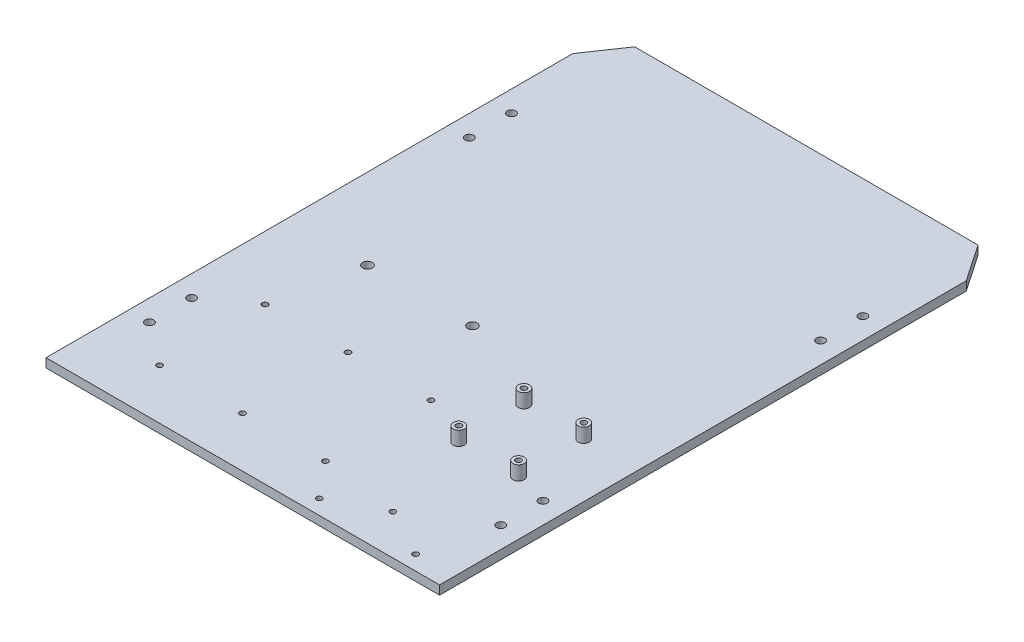
from build123d import *

# Parameters (mm, degrees)
SKETCH2_R           = 2
SKETCH2_R_2         = 3.455
SKETCH2_R_3         = 3
BOSS_EXTRUDE1_DEPTH = 6.35
SKETCH3_R           = 4
SKETCH3_R_2         = 2
BOSS_EXTRUDE2_DEPTH = 10


with BuildPart() as part:
    # Sketch2 → Boss-Extrude1 (new body)
    with BuildSketch(Plane(origin=(0, 0, 0), x_dir=(1, 0, 0), z_dir=(0, 1, 0))):
        Polygon((0, 0), (280, 0), (280, 374.8), (262.142723834, 401.006270851), (140, 401.01), (17.857276166, 401.006270851), (0, 374.8), align=None)
        with Locations((45.125976945, 35.709590933)):
            Circle(SKETCH2_R, mode=Mode.SUBTRACT)
        with Locations((45.125976945, 110.709590933)):
            Circle(SKETCH2_R, mode=Mode.SUBTRACT)
        with Locations((104.125976945, 35.709590933)):
            Circle(SKETCH2_R, mode=Mode.SUBTRACT)
        with Locations((104.125976945, 110.709590933)):
            Circle(SKETCH2_R, mode=Mode.SUBTRACT)
        with Locations((163.125976945, 35.709590933)):
            Circle(SKETCH2_R, mode=Mode.SUBTRACT)
        with Locations((163.125976945, 110.709590933)):
            Circle(SKETCH2_R, mode=Mode.SUBTRACT)
        with Locations((57.382352913, 171.377840784)):
            Circle(SKETCH2_R_2, mode=Mode.SUBTRACT)
        with Locations((132.032352913, 171.377840784)):
            Circle(SKETCH2_R_2, mode=Mode.SUBTRACT)
        with Locations((252.523722024, 10.5)):
            Circle(SKETCH2_R, mode=Mode.SUBTRACT)
        with Locations((218.233722024, 28.5)):
            Circle(SKETCH2_R, mode=Mode.SUBTRACT)
        with Locations((183.943722024, 10.5)):
            Circle(SKETCH2_R, mode=Mode.SUBTRACT)
        with Locations((265, 88.605509424)):
            Circle(SKETCH2_R_3, mode=Mode.SUBTRACT)
        with Locations((265, 58.605509424)):
            Circle(SKETCH2_R_3, mode=Mode.SUBTRACT)
        with Locations((15, 58.605509424)):
            Circle(SKETCH2_R_3, mode=Mode.SUBTRACT)
        with Locations((15, 88.605509424)):
            Circle(SKETCH2_R_3, mode=Mode.SUBTRACT)
        with Locations((265, 316.194490576)):
            Circle(SKETCH2_R_3, mode=Mode.SUBTRACT)
        with Locations((265, 286.194490576)):
            Circle(SKETCH2_R_3, mode=Mode.SUBTRACT)
        with Locations((15, 316.194490576)):
            Circle(SKETCH2_R_3, mode=Mode.SUBTRACT)
        with Locations((15, 286.194490576)):
            Circle(SKETCH2_R_3, mode=Mode.SUBTRACT)
    extrude(amount=BOSS_EXTRUDE1_DEPTH)

    # Sketch3 → Boss-Extrude2 (add)
    with BuildSketch(Plane(origin=(0, 6.35, 0), x_dir=(1, 0, 0), z_dir=(0, 1, 0))):
        with Locations((241.321633488, 94.932700401)):
            Circle(SKETCH3_R)
        with Locations((241.321633488, 94.932700401)):
            Circle(SKETCH3_R_2, mode=Mode.SUBTRACT)
        with Locations((198.776633488, 94.932700401)):
            Circle(SKETCH3_R)
        with Locations((198.776633488, 94.932700401)):
            Circle(SKETCH3_R_2, mode=Mode.SUBTRACT)
        with Locations((198.776633488, 141.287700401)):
            Circle(SKETCH3_R)
        with Locations((198.776633488, 141.287700401)):
            Circle(SKETCH3_R_2, mode=Mode.SUBTRACT)
        with Locations((241.321633488, 141.287700401)):
            Circle(SKETCH3_R)
        with Locations((241.321633488, 141.287700401)):
            Circle(SKETCH3_R_2, mode=Mode.SUBTRACT)
    extrude(amount=BOSS_EXTRUDE2_DEPTH)


solid = part.part
